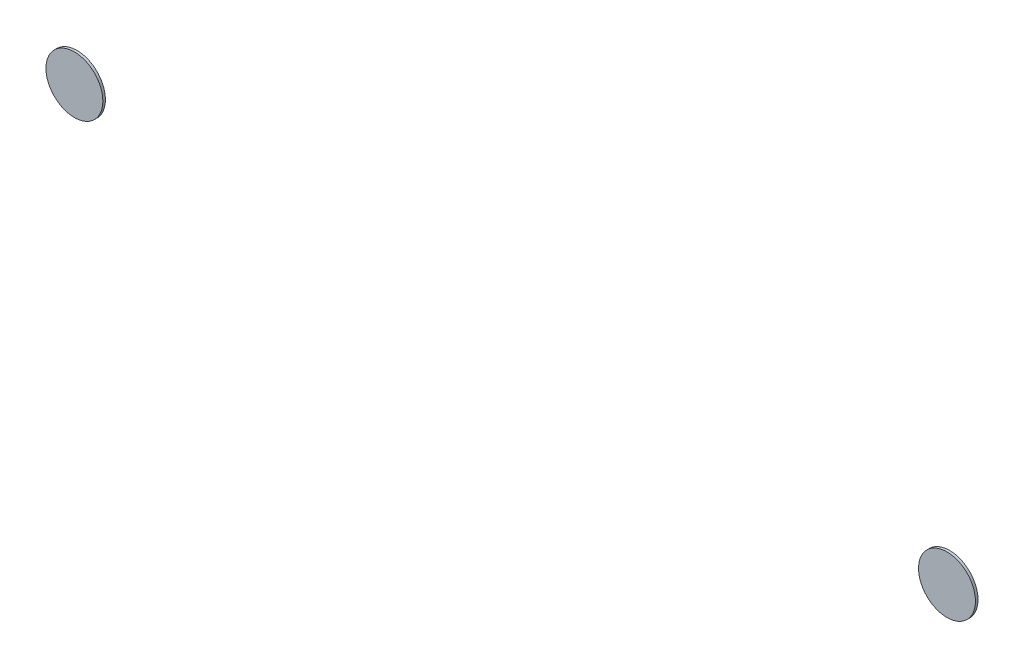
from build123d import *

# Parameters (mm, degrees)
MODEL_R                   = 1.105480949
SALIENTE_EXTRUIR1_DEPTH   = 0.1
SALIENTE_EXTRUIR1_2_DEPTH = 0.1


with BuildPart() as part:
    # Model → Saliente-Extruir1 (new body)
    with BuildSketch(Plane.XY):
        with Locations((39.252272992, 19.763887994)):
            Circle(MODEL_R)
    extrude(amount=SALIENTE_EXTRUIR1_DEPTH)


with BuildPart() as body_2:
    # Model → Saliente-Extruir1 2 (new body)
    with BuildSketch(Plane.XY):
        with Locations((5.347727008, 19.636112006)):
            Circle(MODEL_R)
    extrude(amount=SALIENTE_EXTRUIR1_2_DEPTH)


solid = Compound([part.part, body_2.part])
